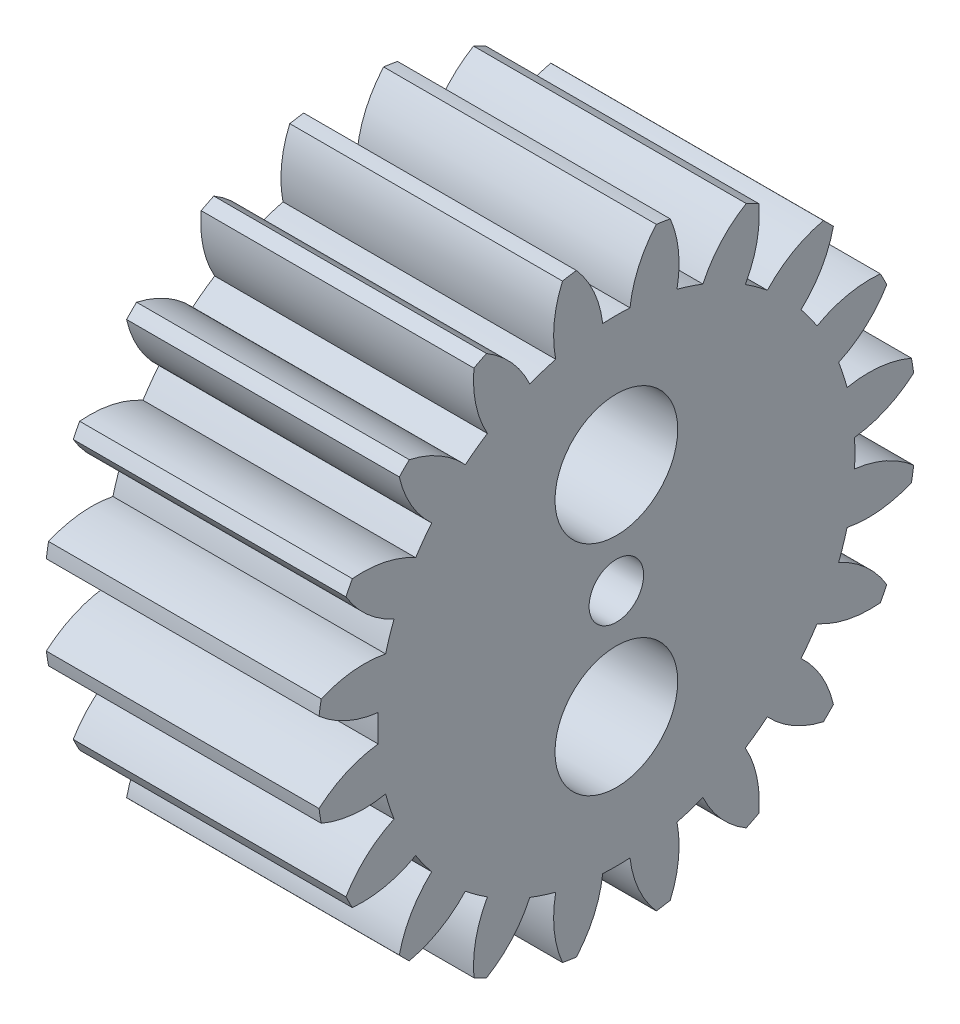
from build123d import *

# Parameters (mm, degrees)
BASPROSKE_W             = 5
BASPROSKE_H             = 5.5
TOOTHCUT_DEPTH          = 10.246621004
TEETHCUTS_COUNT         = 20
TEETHCUTS_ANGLE         = 342
BORSKE_R                = 0.5
BORE_DEPTH              = 50.0000508
SKETCH1_R               = 1.125
CUT_EXTRUDE1_DEPTH      = 10.188413972
CUT_EXTRUDE1_DEPTH_BACK = 10.188413972


with BuildPart() as part:
    # BasProSke → Base-Revolve (revolve)
    with BuildSketch(Plane(origin=(0, 0, 0), x_dir=(1, 0, 0), z_dir=(0, 1, 0)), mode=Mode.PRIVATE) as base_revolve_sk:
        with Locations((2.5, 2.75)):
            Rectangle(BASPROSKE_W, BASPROSKE_H)
    revolve(base_revolve_sk.sketch.rotate(Axis((-10, 0, 0), (1, 0, 0)), 180), axis=Axis((-10, 0, 0), (1, 0, 0)))

    # TooCutSke → ToothCut (cut, through all)
    with BuildSketch(Plane(origin=(0, 0, 0), x_dir=(0, 0, -1), z_dir=(1, 0, 0))):
        with BuildLine():
            ThreePointArc((0.249903181, 4.366855207), (0, 4.374), (-0.249903181, 4.366855207))
            ThreePointArc((-0.249903181, 4.366855207), (-0.415207844, 4.95951031), (-0.752843848, 5.473871692))
            ThreePointArc((-0.752843848, 5.473871692), (0, 5.5254), (0.752843848, 5.473871692))
            ThreePointArc((0.752843848, 5.473871692), (0.415207844, 4.95951031), (0.249903181, 4.366855207))
        make_face()
    toothcut = extrude(amount=TOOTHCUT_DEPTH, mode=Mode.SUBTRACT)

    # TeethCuts: ToothCut ×20 about axis
    teethcuts_axis = Axis((-10, 0, 0), (1, 0, 0))
    for i in range(1, TEETHCUTS_COUNT):
        add(toothcut.rotate(teethcuts_axis, i * TEETHCUTS_ANGLE / (TEETHCUTS_COUNT - 1)), mode=Mode.SUBTRACT)

    # BorSke → Bore (cut, symmetric)
    with BuildSketch(Plane(origin=(0, 0, 0), x_dir=(0, 0, -1), z_dir=(1, 0, 0))):
        with Locations(Location((0, 0, 0), (0, 0, 180))):
            Circle(BORSKE_R)
    extrude(amount=BORE_DEPTH, both=True, mode=Mode.SUBTRACT)

    # Sketch1 → Cut-Extrude1 (cut, two sides)
    with BuildSketch(Plane(origin=(5, 0, 0), x_dir=(0, 0, -1), z_dir=(1, 0, 0))) as cut_extrude1_sk:
        with Locations((0, 2)):
            Circle(SKETCH1_R)
        with Locations((0, -2)):
            Circle(SKETCH1_R)
    extrude(amount=CUT_EXTRUDE1_DEPTH, mode=Mode.SUBTRACT)
    extrude(cut_extrude1_sk.sketch, amount=-CUT_EXTRUDE1_DEPTH_BACK, mode=Mode.SUBTRACT)


solid = part.part
